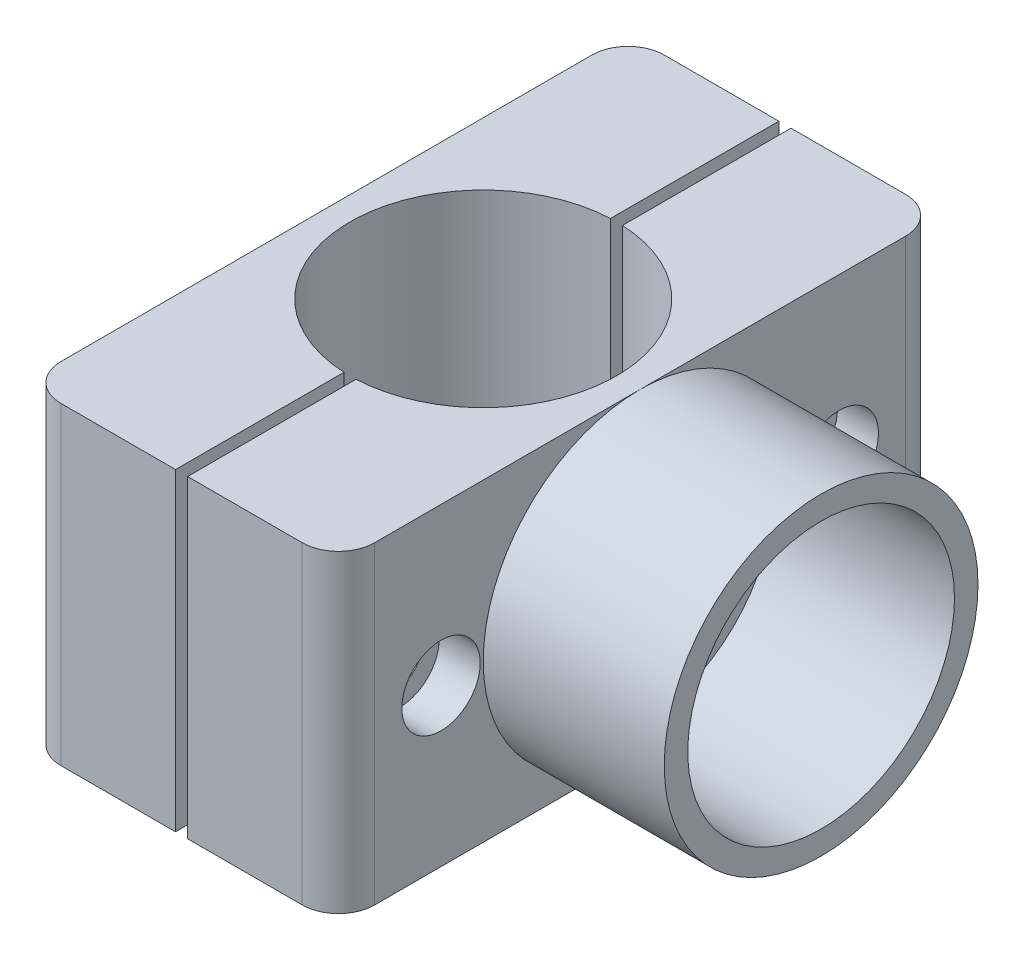
from build123d import *

# Parameters (mm, degrees)
CROQUIS1_W                                           = 26
CROQUIS1_H                                           = 50
CROQUIS1_R                                           = 11.05
SALIENTE_EXTRUIR3_DEPTH                              = 26
REFRENTADO_PARA_TORNILLO_CON_CABEZA_HUEC_D           = 3.4
REFRENTADO_PARA_TORNILLO_CON_CABEZA_HUEC_CBORE_D     = 6.5
REFRENTADO_PARA_TORNILLO_CON_CABEZA_HUEC_CBORE_DEPTH = 3.4
CROQUIS26_W                                          = 1
CROQUIS26_H                                          = 26
CORTAR_EXTRUIR2_DEPTH                                = 51
CORTAR_EXTRUIR3_DEPTH                                = 3
CROQUIS28_R                                          = 13
CROQUIS28_R_2                                        = 11.05
SALIENTE_EXTRUIR4_DEPTH                              = 15
REDONDEO1_R                                          = 3
REDONDEO2_R                                          = 3


with BuildPart() as part:
    # Croquis1 → Saliente-Extruir3 (new body)
    with BuildSketch(Plane(origin=(0, 0, 0), x_dir=(1, 0, 0), z_dir=(0, 1, 0))):
        Rectangle(CROQUIS1_W, CROQUIS1_H)
        Circle(CROQUIS1_R, mode=Mode.SUBTRACT)
    extrude(amount=SALIENTE_EXTRUIR3_DEPTH)

    # Refrentado para tornillo con cabeza hueca de M31 (through all)
    with Locations(Plane(origin=(13, 0, 0), x_dir=(0, 0, -1), z_dir=(1, 0, 0))):
        with Locations((-16.5, 13), (16.5, 13)):
            CounterBoreHole(REFRENTADO_PARA_TORNILLO_CON_CABEZA_HUEC_D / 2, REFRENTADO_PARA_TORNILLO_CON_CABEZA_HUEC_CBORE_D / 2, REFRENTADO_PARA_TORNILLO_CON_CABEZA_HUEC_CBORE_DEPTH)

    # Croquis26 → Cortar-Extruir2 (cut, through all)
    with BuildSketch(Plane.XY.offset(25)):
        with Locations((0, 13)):
            Rectangle(CROQUIS26_W, CROQUIS26_H)
    extrude(amount=-CORTAR_EXTRUIR2_DEPTH, mode=Mode.SUBTRACT)

    # Croquis27 → Cortar-Extruir3 (cut)
    with BuildSketch(Plane.ZY.offset(13)):
        Polygon((-13.035898385, 13), (-14.767949192, 16), (-18.232050808, 16), (-19.964101615, 13), (-18.232050808, 10), (-14.767949192, 10), align=None)
    cortar_extruir3 = extrude(amount=-CORTAR_EXTRUIR3_DEPTH, mode=Mode.SUBTRACT)

    # Simetría8: Cortar-Extruir3 across plane
    add(cortar_extruir3.mirror(Plane.XY), mode=Mode.SUBTRACT)

    # Croquis28 → Saliente-Extruir4 (add)
    with BuildSketch(Plane(origin=(13, 0, 0), x_dir=(0, 0, -1), z_dir=(1, 0, 0))):
        with Locations((0, 13)):
            Circle(CROQUIS28_R)
        with Locations((0, 13)):
            Circle(CROQUIS28_R_2, mode=Mode.SUBTRACT)
    extrude(amount=SALIENTE_EXTRUIR4_DEPTH)

    # Redondeo1
    redondeo1_edges = [part.edges().sort_by_distance(p)[0] for p in [
        (13, 13, 25),
        (13, 13, -25),
    ]]
    fillet(redondeo1_edges, radius=REDONDEO1_R)

    # Redondeo2
    redondeo2_edges = [part.edges().sort_by_distance(p)[0] for p in [
        (-13, 13, 25),
        (-13, 13, -25),
    ]]
    fillet(redondeo2_edges, radius=REDONDEO2_R)


solid = part.part
